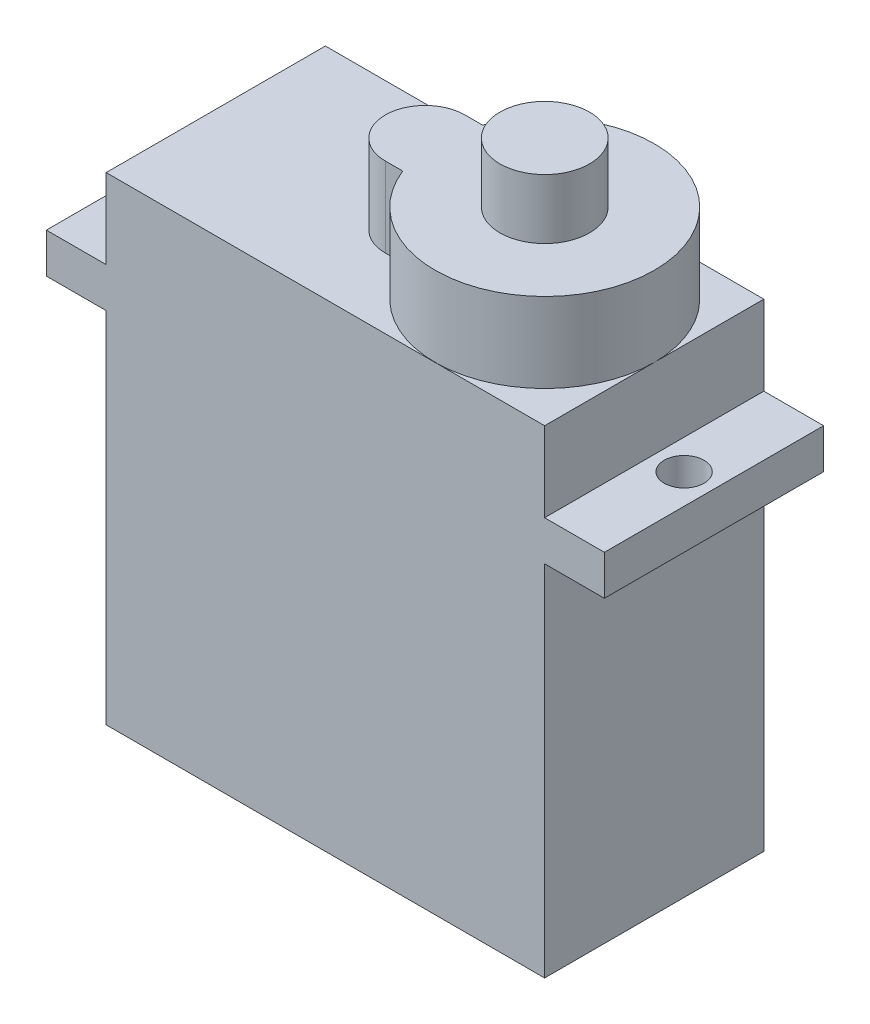
from build123d import *

# Parameters (mm, degrees)
SKETCH1_W           = 22
SKETCH1_H           = 11
BOSS_EXTRUDE1_DEPTH = 24
BOSS_EXTRUDE2_DEPTH = 4
SKETCH4_W           = 11
SKETCH4_H           = 2
BOSS_EXTRUDE3_DEPTH = 3
SKETCH5_R           = 1
CUT_EXTRUDE2_DEPTH  = 21
SKETCH3_R           = 2.25
BOSS_EXTRUDE4_DEPTH = 3


with BuildPart() as part:
    # Sketch1 → Boss-Extrude1 (new body)
    with BuildSketch(Plane(origin=(0, 0, 0), x_dir=(1, 0, 0), z_dir=(0, 1, 0))):
        Rectangle(SKETCH1_W, SKETCH1_H)
    extrude(amount=BOSS_EXTRUDE1_DEPTH)

    # Sketch2 → Boss-Extrude2 (add)
    with BuildSketch(Plane(origin=(0, 24, 0), x_dir=(1, 0, 0), z_dir=(0, 1, 0))):
        with BuildLine():
            Line((-0.5, 2.006506876), (0.376524617, 2.006506876))
            ThreePointArc((0.376524617, 2.006506876), (11, 0.006506876), (0.376524617, -1.993493124))
            Line((0.376524617, -1.993493124), (-0.5, -1.993493124))
            ThreePointArc((-0.5, -1.993493124), (-2.5, 0.006506876), (-0.5, 2.006506876))
        make_face()
    extrude(amount=BOSS_EXTRUDE2_DEPTH)

    # Sketch4 → Boss-Extrude3 (add)
    with BuildSketch(Plane.ZY.offset(11)):
        with Locations((0, 19)):
            Rectangle(SKETCH4_W, SKETCH4_H)
    boss_extrude3 = extrude(amount=BOSS_EXTRUDE3_DEPTH)

    # Sketch5 → Cut-Extrude2 (cut, through all)
    with BuildSketch(Plane(origin=(0, 20, 0), x_dir=(1, 0, 0), z_dir=(0, 1, 0))):
        with Locations((-12.5, 0)):
            Circle(SKETCH5_R)
    cut_extrude2 = extrude(amount=-CUT_EXTRUDE2_DEPTH, mode=Mode.SUBTRACT)

    # Mirror1: Boss-Extrude3, Cut-Extrude2 across plane
    add(boss_extrude3.mirror(Plane(origin=(0, 0, 0), x_dir=(0, 0, 1), z_dir=(1, 0, 0))))
    add(cut_extrude2.mirror(Plane(origin=(0, 0, 0), x_dir=(0, 0, 1), z_dir=(1, 0, 0))), mode=Mode.SUBTRACT)

    # Sketch3 → Boss-Extrude4 (add)
    with BuildSketch(Plane(origin=(0, 28, 0), x_dir=(1, 0, 0), z_dir=(0, 1, 0))):
        with Locations((5.5, 0.006506876)):
            Circle(SKETCH3_R)
    extrude(amount=BOSS_EXTRUDE4_DEPTH)


solid = part.part
